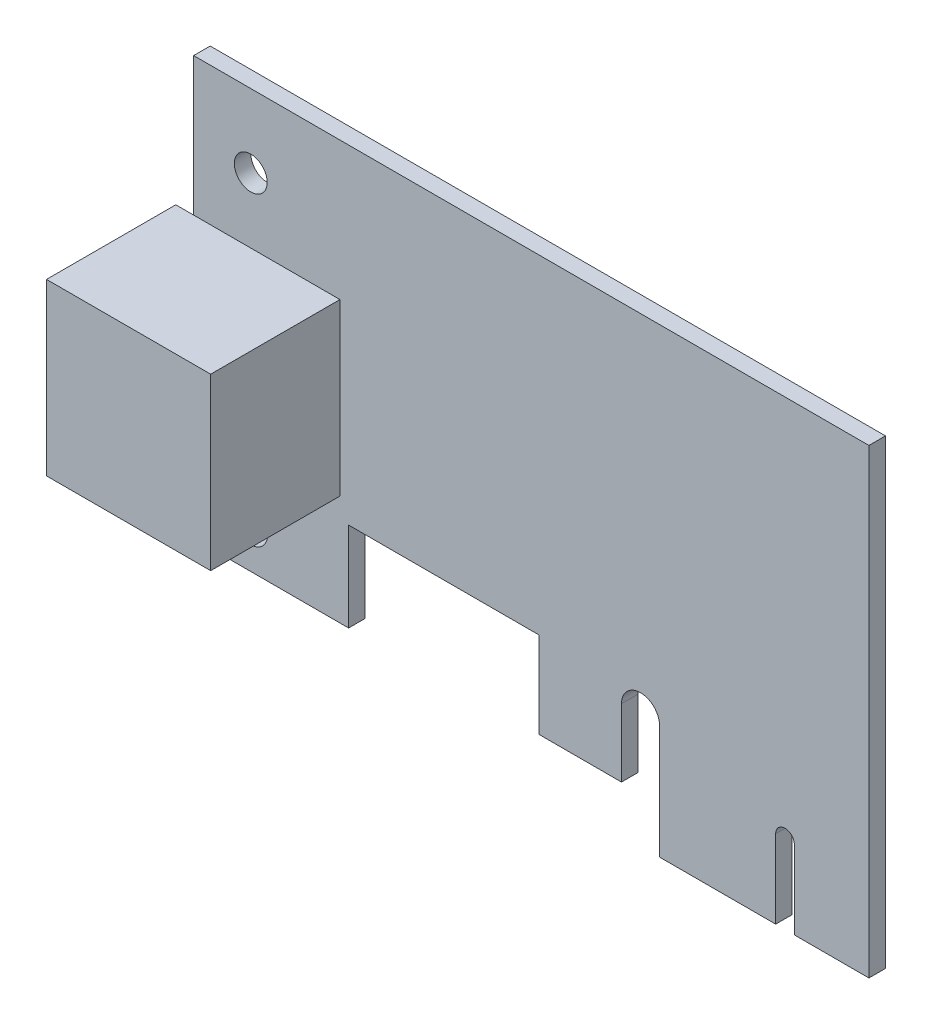
from build123d import *

# Parameters (mm, degrees)
SKETCH2_R           = 1.5875
BOSS_EXTRUDE1_DEPTH = 1.6
SKETCH3_W           = 15.875
SKETCH3_H           = 16.4592
BOSS_EXTRUDE2_DEPTH = 12.5


with BuildPart() as part:
    # Sketch2 → Boss-Extrude1 (new body)
    with BuildSketch(Plane.XY):
        with BuildLine():
            Line((0, 4.1529), (14.986, 4.1529))
            Line((14.986, 4.1529), (14.986, 12.7762))
            Line((14.986, 12.7762), (33.3756, 12.7762))
            Line((33.3756, 12.7762), (33.3756, 4.445))
            Line((33.3756, 4.445), (41.3766, 4.445))
            Line((41.3766, 4.445), (41.3766, 11.0109))
            ThreePointArc((41.3766, 11.0109), (43.2181, 12.8524), (45.0596, 11.0109))
            Line((45.0596, 11.0109), (45.0596, 0))
            Line((45.0596, 0), (56.2864, 0))
            Line((56.2864, 0), (56.2864, 7.5819))
            ThreePointArc((56.2864, 7.5819), (57.1881, 8.4836), (58.0898, 7.5819))
            Line((58.0898, 7.5819), (58.0898, 0))
            Line((58.0898, 0), (65.3034, 0))
            Line((65.3034, 0), (65.3034, 44.6024))
            Line((65.3034, 44.6024), (0, 44.6024))
            Line((0, 44.6024), (0, 4.1529))
        make_face()
        with Locations((5.5245, 37.5285)):
            Circle(SKETCH2_R, mode=Mode.SUBTRACT)
        with Locations((5.55, 7.9883)):
            Circle(SKETCH2_R, mode=Mode.SUBTRACT)
    extrude(amount=BOSS_EXTRUDE1_DEPTH)

    # Sketch3 → Boss-Extrude2 (add)
    with BuildSketch(Plane.XY.offset(1.6)):
        with Locations((6.2103, 23.0124)):
            Rectangle(SKETCH3_W, SKETCH3_H)
    extrude(amount=BOSS_EXTRUDE2_DEPTH)


solid = part.part
